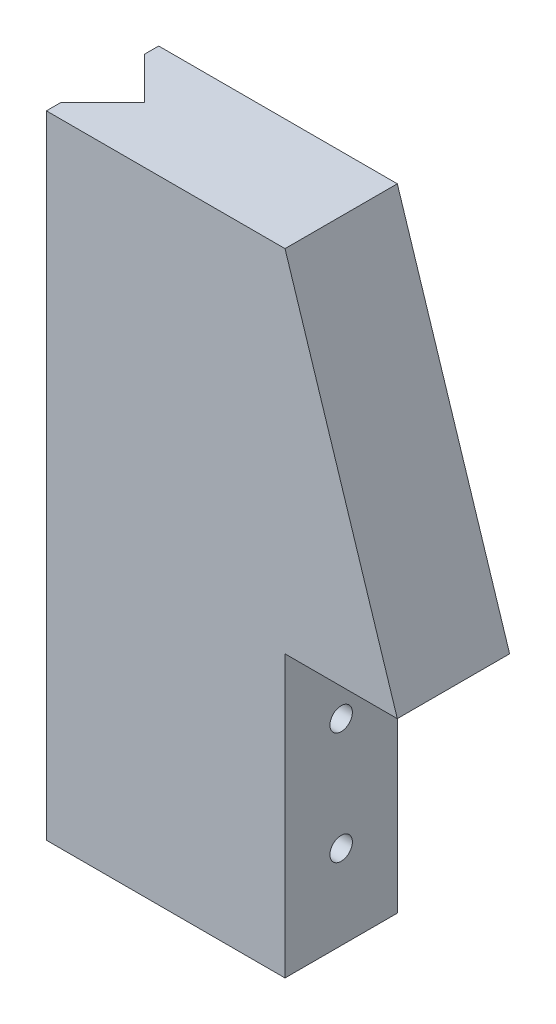
from build123d import *

# Parameters (mm, degrees)
BOSS_EXTRUDE1_DEPTH       = 8
CUT_EXTRUDE1_DEPTH        = 46
M2X0_4_TAPPED_HOLE1_D     = 1.6
M2X0_4_TAPPED_HOLE1_DEPTH = 5
M2X0_4_TAPPED_HOLE1_TIP   = 0.480688495


with BuildPart() as part:
    # Sketch1 → Boss-Extrude1 (new body)
    with BuildSketch(Plane.XY):
        Polygon((0, 0), (-8, 0), (-8, -20), (-25, -20), (-25, 25), (-8, 25), align=None)
    extrude(amount=BOSS_EXTRUDE1_DEPTH)

    # Sketch2 → Cut-Extrude1 (cut, through all)
    with BuildSketch(Plane(origin=(0, 25, 0), x_dir=(1, 0, 0), z_dir=(0, 1, 0))):
        Polygon((-25, -4), (-25, -1), (-22, -4), (-25, -7), align=None)
    extrude(amount=-CUT_EXTRUDE1_DEPTH, mode=Mode.SUBTRACT)

    # M2x0.4 Tapped Hole1
    with Locations(Plane(origin=(-8, -6, 4), x_dir=(0, 0, 1), z_dir=(1, 0, 0))):
        with Locations((0, 0), (0, 8)):
            Hole(M2X0_4_TAPPED_HOLE1_D / 2, depth=M2X0_4_TAPPED_HOLE1_DEPTH)
            with Locations((0, 0, -(M2X0_4_TAPPED_HOLE1_DEPTH + M2X0_4_TAPPED_HOLE1_TIP / 2))):  # 118° drill point
                Cone(0, M2X0_4_TAPPED_HOLE1_D / 2, M2X0_4_TAPPED_HOLE1_TIP, mode=Mode.SUBTRACT)


solid = part.part
